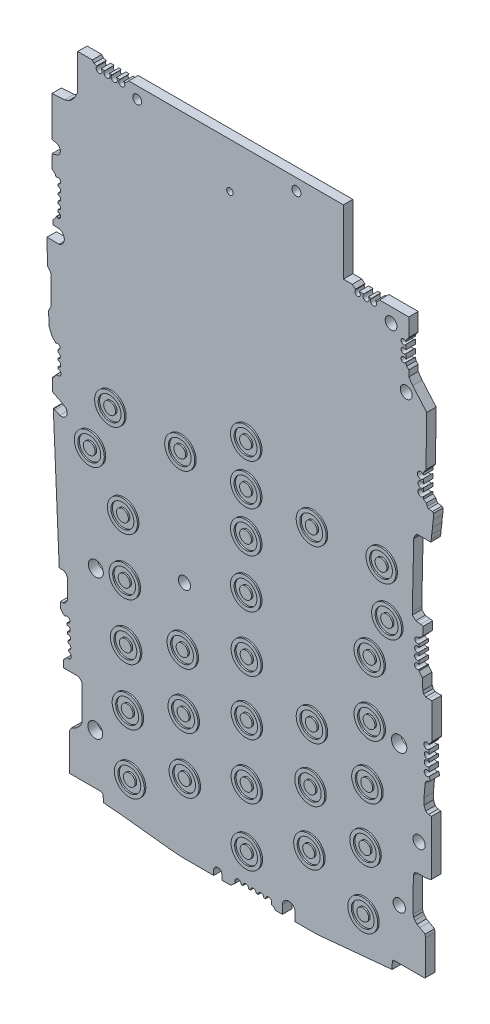
from build123d import *

# Parameters (mm, degrees)
PCBMAIN_R          = 0.760209253
PCBMAIN_R_2        = 0.759129565
PCBMAIN_R_3        = 0.996602967
PCBMAIN_R_4        = 1.012822949
PCBMAIN_R_5        = 0.551193265
PCBMAIN_R_6        = 1.025383556
PCBMAIN_R_7        = 1.032267377
PCBMAIN_R_8        = 1.041760337
PCBMAIN_R_9        = 1.256983707
PCBMAIN_R_10       = 1.269539046
PCBMAIN_R_11       = 1.299761266
BOSS_EXTRU_1_DEPTH = 1.6
BUTTONS_R          = 2.542017241
BUTTONS_R_2        = 1.938980707
BUTTONS_R_3        = 1.002648756
BOSS_EXTRU_2_DEPTH = 0.25


with BuildPart() as part:
    # pcbmain → Boss.-Extru.1 (new body)
    with BuildSketch(Plane.XY):
        with BuildLine():
            Line((-26.347160338, 56.329284646), (-23.927618791, 56.329284646))
            Line((-23.927618791, 56.329284646), (-23.664647578, 55.952821554))
            Line((-23.664647578, 55.952821554), (-23.201317346, 55.80255229))
            Line((-23.201317346, 55.80255229), (-23.128187119, 55.80255229))
            ThreePointArc((-23.128187119, 55.80255229), (-22.781212925, 54.930096236), (-22.434238731, 55.80255229))
            Line((-22.434238731, 55.80255229), (-21.828313295, 55.80255229))
            ThreePointArc((-21.828313295, 55.80255229), (-21.432210012, 54.909796767), (-21.036106729, 55.80255229))
            Line((-21.036106729, 55.80255229), (-20.591897878, 55.80255229))
            ThreePointArc((-20.591897878, 55.80255229), (-20.224453231, 54.890639566), (-19.857008583, 55.80255229))
            Line((-19.857008583, 55.80255229), (-19.266480451, 55.80255229))
            ThreePointArc((-19.266480451, 55.80255229), (-18.948553836, 54.880571738), (-18.630627221, 55.80255229))
            Line((-18.630627221, 55.80255229), (-18.279998937, 55.80255229))
            Line((-18.279998937, 55.80255229), (-17.77284017, 56.329284646))
            Line((-17.77284017, 56.329284646), (18.595018705, 56.329284646))
            Line((18.595018705, 56.329284646), (18.595018705, 45.429755694))
            Line((18.595018705, 45.429755694), (20.11132037, 45.429755694))
            Line((20.11132037, 45.429755694), (20.630107953, 44.97217823))
            Line((20.630107953, 44.97217823), (20.721658703, 44.97217823))
            ThreePointArc((20.721658703, 44.97217823), (20.992920184, 44.111471008), (21.264181665, 44.97217823))
            Line((21.264181665, 44.97217823), (22.033886118, 44.97217823))
            ThreePointArc((22.033886118, 44.97217823), (22.435692187, 44.083717269), (22.837498256, 44.97217823))
            Line((22.837498256, 44.97217823), (23.325768922, 44.97217823))
            ThreePointArc((23.325768922, 44.97217823), (23.685190384, 44.056278982), (24.044611847, 44.97217823))
            Line((24.044611847, 44.97217823), (24.431159458, 45.050165905))
            Line((24.431159458, 45.050165905), (24.705811707, 45.429755694))
            Line((24.705811707, 45.429755694), (29.675798929, 45.429755694))
            Line((29.675798929, 45.429755694), (29.675798929, 42.4053954))
            Line((29.675798929, 42.4053954), (29.182053315, 41.772560318))
            Line((29.182053315, 41.772560318), (29.182053315, 41.532362636))
            ThreePointArc((29.182053315, 41.532362636), (28.363974279, 41.344689092), (29.182053315, 41.157015548))
            Line((29.182053315, 41.157015548), (29.182053315, 40.343285981))
            ThreePointArc((29.182053315, 40.343285981), (28.359033494, 40.062491976), (29.182053315, 39.781697971))
            Line((29.182053315, 39.781697971), (29.182053315, 38.96510316))
            ThreePointArc((29.182053315, 38.96510316), (28.370622263, 38.728720451), (29.182053315, 38.492337743))
            Line((29.182053315, 38.492337743), (29.182053315, 38.433809714))
            Line((29.182053315, 38.433809714), (29.298436778, 37.997371726))
            Line((29.298436778, 37.997371726), (29.675798929, 37.655495303))
            Line((29.675798929, 37.655495303), (29.675798929, 36.627711227))
            Line((29.675798929, 36.627711227), (30.33297601, 35.686418365))
            Line((30.33297601, 35.686418365), (32.119853137, 33.617402745))
            Line((32.119853137, 33.617402745), (32.7131208, 32.930461239))
            Line((32.7131208, 32.930461239), (32.584297057, 24.478056045))
            Line((32.584297057, 24.478056045), (32.165274176, 23.839010992))
            Line((32.165274176, 23.839010992), (32.165274176, 23.430489137))
            ThreePointArc((32.165274176, 23.430489137), (31.135756508, 23.192400566), (32.165274176, 22.954311994))
            Line((32.165274176, 22.954311994), (32.165274176, 22.156317438))
            ThreePointArc((32.165274176, 22.156317438), (31.220854764, 21.883359432), (32.165274176, 21.610401425))
            Line((32.165274176, 21.610401425), (32.148127992, 20.964451154))
            ThreePointArc((32.148127992, 20.964451154), (31.212303724, 20.625077263), (32.148127992, 20.285703371))
            Line((32.148127992, 20.285703371), (32.165274176, 20.285703371))
            Line((32.165274176, 20.285703371), (32.165274176, 19.908565197))
            Line((32.165274176, 19.908565197), (32.630485989, 19.603525054))
            Line((32.630485989, 19.603525054), (32.804035512, 19.187083471))
            ThreePointArc((32.804035512, 19.187083471), (32.892709628, 19.053604885), (33.024845703, 18.962942383))
            Line((33.024845703, 18.962942383), (33.68655575, 18.892171255))
            Line((33.68655575, 18.892171255), (33.875985234, 18.716994969))
            Line((33.875985234, 18.716994969), (33.875985234, 17.80583444))
            Line((33.875985234, 17.80583444), (33.781270492, 17.80583444))
            Line((33.781270492, 17.80583444), (33.708220342, 16.575711613))
            Line((33.708220342, 16.575711613), (33.553914832, 15.418963886))
            Line((33.553914832, 15.418963886), (33.497779339, 14.741595603))
            Line((33.497779339, 14.741595603), (33.400128649, 14.251477155))
            Line((33.400128649, 14.251477155), (31.002556808, 14.251477155))
            Line((31.002556808, 14.251477155), (30.697220834, 13.785814174))
            Line((30.697220834, 13.785814174), (30.520636829, 13.392132333))
            Line((30.520636829, 13.392132333), (30.506039307, 13.215988906))
            Line((30.506039307, 13.215988906), (30.273104425, 2.473562529))
            Line((30.273104425, 2.473562529), (30.273104425, 1.988804395))
            Line((30.273104425, 1.988804395), (30.52208686, 1.758556085))
            Line((30.52208686, 1.758556085), (30.849888821, 1.455418848))
            Line((30.849888821, 1.455418848), (31.099307686, 1.405724892))
            Line((31.099307686, 1.405724892), (31.692843962, 1.356536803))
            Line((31.692843962, 1.356536803), (32.119853137, 1.271459939))
            Line((32.119853137, 1.271459939), (32.119853137, -0.124452781))
            Line((32.119853137, -0.124452781), (31.85383624, -0.354194647))
            Line((31.85383624, -0.354194647), (31.725758852, -0.549523411))
            Line((31.725758852, -0.549523411), (31.396075824, -0.686916827))
            Line((31.396075824, -0.686916827), (31.396075824, -0.913696889))
            ThreePointArc((31.396075824, -0.913696889), (30.681699235, -1.299026746), (31.396075824, -1.684356603))
            Line((31.396075824, -1.684356603), (31.396075824, -2.219700374))
            ThreePointArc((31.396075824, -2.219700374), (30.651157623, -2.575615737), (31.396075824, -2.931531101))
            Line((31.396075824, -2.931531101), (31.396075824, -3.425694582))
            ThreePointArc((31.396075824, -3.425694582), (30.640193016, -3.761019801), (31.396075824, -4.09634502))
            Line((31.396075824, -4.09634502), (31.396075824, -4.710368663))
            ThreePointArc((31.396075824, -4.710368663), (30.645561021, -5.077760093), (31.396075824, -5.445151523))
            Line((31.396075824, -5.445151523), (31.396075824, -5.653977426))
            Line((31.396075824, -5.653977426), (31.986844688, -6.338025585))
            Line((31.986844688, -6.338025585), (32.049056444, -8.19424299))
            Line((32.049056444, -8.19424299), (32.201342728, -8.651620718))
            Line((32.201342728, -8.651620718), (32.552324294, -8.881759902))
            Line((32.552324294, -8.881759902), (32.97533873, -8.916816346))
            Line((32.97533873, -8.916816346), (33.631067587, -8.916816346))
            Line((33.631067587, -8.916816346), (33.631067587, -14.886392836))
            Line((33.631067587, -14.886392836), (33.133289274, -15.509264135))
            Line((33.133289274, -15.509264135), (33.133289274, -15.613477346))
            ThreePointArc((33.133289274, -15.613477346), (32.240921556, -15.947205939), (33.133289274, -16.280934532))
            Line((33.133289274, -16.280934532), (33.133289274, -17.001434673))
            ThreePointArc((33.133289274, -17.001434673), (32.306209244, -17.319692403), (33.133289274, -17.637950134))
            Line((33.133289274, -17.637950134), (33.133289274, -18.186060671))
            ThreePointArc((33.133289274, -18.186060671), (32.299780119, -18.515369018), (33.133289274, -18.844677364))
            Line((33.133289274, -18.844677364), (33.133289274, -19.622640706))
            ThreePointArc((33.133289274, -19.622640706), (32.28219796, -19.941620213), (33.133289274, -20.26059972))
            Line((33.133289274, -20.26059972), (33.318842066, -20.817890321))
            Line((33.318842066, -20.817890321), (33.133289274, -20.97814046))
            Line((33.133289274, -20.97814046), (32.763831512, -21.101153335))
            Line((32.763831512, -21.101153335), (32.478949459, -21.45762699))
            Line((32.478949459, -21.45762699), (32.429964541, -21.703487125))
            Line((32.429964541, -21.703487125), (32.254768798, -23.817515757))
            Line((32.254768798, -23.817515757), (32.254768798, -24.910601341))
            Line((32.254768798, -24.910601341), (32.552324294, -25.624602049))
            Line((32.552324294, -25.624602049), (33.024845703, -25.895512052))
            Line((33.024845703, -25.895512052), (33.497779339, -25.934705447))
            Line((33.497779339, -25.934705447), (33.497779339, -35.190955042))
            Line((33.497779339, -35.190955042), (33.182319476, -35.32242104))
            Line((33.182319476, -35.32242104), (32.552324294, -35.41982665))
            Line((32.552324294, -35.41982665), (31.099307686, -35.41982665))
            Line((31.099307686, -35.41982665), (30.685987841, -35.592075206))
            Line((30.685987841, -35.592075206), (30.49409695, -35.926771429))
            Line((30.49409695, -35.926771429), (30.439368275, -36.201460044))
            Line((30.439368275, -36.201460044), (30.397595643, -41.788285256))
            Line((30.397595643, -41.788285256), (30.49409695, -42.243872097))
            Line((30.49409695, -42.243872097), (30.730517934, -42.582504394))
            Line((30.730517934, -42.582504394), (31.071644863, -42.97749347))
            Line((31.071644863, -42.97749347), (31.534036135, -43.242595576))
            Line((31.534036135, -43.242595576), (32.42996454, -43.734673871))
            Line((32.42996454, -43.734673871), (32.525500542, -44.185703465))
            Line((32.525500542, -44.185703465), (32.481143689, -50.118151883))
            Line((32.481143689, -50.118151883), (32.342366669, -50.215041045))
            Line((32.342366669, -50.215041045), (27.120149976, -50.215041045))
            Line((27.120149976, -50.215041045), (26.924465275, -50.384041469))
            Line((26.924465275, -50.384041469), (26.877788359, -50.618317516))
            Line((26.877788359, -50.618317516), (26.853968453, -51.716837329))
            Line((26.853968453, -51.716837329), (14.071547847, -52.924255816))
            Line((14.071547847, -52.924255816), (12.489702367, -52.924255816))
            Line((12.489702367, -52.924255816), (10.424778327, -52.924255816))
            Line((10.424778327, -52.924255816), (10.424778327, -51.512908651))
            ThreePointArc((10.424778327, -51.512908651), (9.344955664, -50.45112345), (8.265133001, -51.512908651))
            Line((8.265133001, -51.512908651), (8.265133001, -52.924255816))
            Line((8.265133001, -52.924255816), (7.07633639, -52.924255816))
            Line((7.07633639, -52.924255816), (6.749271755, -52.545549397))
            Line((6.749271755, -52.545549397), (6.459079051, -52.415384922))
            Line((6.459079051, -52.415384922), (6.459079051, -52.056713226))
            ThreePointArc((6.459079051, -52.056713226), (5.944041711, -51.530700307), (5.429004372, -52.056713226))
            Line((5.429004372, -52.056713226), (5.090721584, -52.056713226))
            ThreePointArc((5.090721584, -52.056713226), (4.629426873, -51.548790173), (4.168132162, -52.056713226))
            Line((4.168132162, -52.056713226), (3.77346891, -52.056713226))
            ThreePointArc((3.77346891, -52.056713226), (3.330113438, -51.546778738), (2.886757966, -52.056713226))
            Line((2.886757966, -52.056713226), (2.538224185, -52.056713226))
            ThreePointArc((2.538224185, -52.056713226), (2.056427487, -51.513404245), (1.574630789, -52.056713226))
            Line((1.574630789, -52.056713226), (1.297853962, -52.056713226))
            ThreePointArc((1.297853962, -52.056713226), (0.758160136, -51.495972188), (0.218466311, -52.056713226))
            Line((0.218466311, -52.056713226), (0.218466311, -52.415384922))
            Line((0.218466311, -52.415384922), (-0.495590455, -53.03207031))
            Line((-0.495590455, -53.03207031), (-1.985948048, -53.03207031))
            Line((-1.985948048, -53.03207031), (-1.985948048, -52.236049074))
            ThreePointArc((-1.985948048, -52.236049074), (-2.674664487, -51.508996718), (-3.363380926, -52.236049074))
            Line((-3.363380926, -52.236049074), (-3.363380926, -53.03207031))
            Line((-3.363380926, -53.03207031), (-8.756146039, -53.03207031))
            Line((-8.756146039, -53.03207031), (-11.011402522, -52.845170602))
            Line((-11.011402522, -52.845170602), (-17.162089801, -52.157450729))
            Line((-17.162089801, -52.157450729), (-19.133309089, -51.937045006))
            Line((-19.133309089, -51.937045006), (-21.33126485, -51.754893976))
            Line((-21.33126485, -51.754893976), (-22.056026337, -51.673857036))
            Line((-22.056026337, -51.673857036), (-22.09015522, -50.65555068))
            Line((-22.09015522, -50.65555068), (-22.176654824, -50.447990142))
            Line((-22.176654824, -50.447990142), (-22.328424078, -50.326701132))
            Line((-22.328424078, -50.326701132), (-22.648894059, -50.262851026))
            Line((-22.648894059, -50.262851026), (-27.79602202, -50.262851026))
            Line((-27.79602202, -50.262851026), (-27.79602202, -43.939529598))
            Line((-27.79602202, -43.939529598), (-27.481398322, -43.459702058))
            Line((-27.481398322, -43.459702058), (-27.052819823, -43.242595576))
            Line((-27.052819823, -43.242595576), (-26.734756314, -43.110044523))
            Line((-26.734756314, -43.110044523), (-26.280142309, -42.687259143))
            Line((-26.280142309, -42.687259143), (-25.90436736, -42.280909312))
            Line((-25.90436736, -42.280909312), (-25.748420404, -41.933236345))
            Line((-25.748420404, -41.933236345), (-25.696524508, -41.817538031))
            Line((-25.696524508, -41.817538031), (-25.652999175, -35.996300256))
            Line((-25.652999175, -35.996300256), (-25.732639991, -35.805197757))
            Line((-25.732639991, -35.805197757), (-25.90436736, -35.606355541))
            Line((-25.90436736, -35.606355541), (-26.056208264, -35.465939564))
            Line((-26.056208264, -35.465939564), (-26.174851421, -35.371123845))
            Line((-26.174851421, -35.371123845), (-26.347160338, -35.293835549))
            Line((-26.347160338, -35.293835549), (-28.835927315, -35.293835549))
            Line((-28.835927315, -35.293835549), (-28.835927315, -34.104342387))
            Line((-28.835927315, -34.104342387), (-28.497476373, -33.812043846))
            Line((-28.497476373, -33.812043846), (-28.280055962, -33.53998512))
            Line((-28.280055962, -33.53998512), (-28.10377817, -33.523334044))
            Line((-28.10377817, -33.523334044), (-27.855783776, -33.523334044))
            ThreePointArc((-27.855783776, -33.523334044), (-27.504215708, -32.952050234), (-27.931681942, -32.435099641))
            Line((-27.931681942, -32.435099641), (-27.950543168, -32.164665767))
            ThreePointArc((-27.950543168, -32.164665767), (-27.567889953, -31.677831784), (-28.014417616, -31.248828455))
            Line((-28.014417616, -31.248828455), (-28.040161873, -30.879705101))
            ThreePointArc((-28.040161873, -30.879705101), (-27.610999445, -30.418524093), (-28.100025068, -30.021381485))
            Line((-28.100025068, -30.021381485), (-28.126566018, -29.640835061))
            ThreePointArc((-28.126566018, -29.640835061), (-27.672421083, -29.156222915), (-28.189439903, -28.739343924))
            Line((-28.189439903, -28.739343924), (-28.214137423, -28.385228763))
            ThreePointArc((-28.214137423, -28.385228763), (-27.724239829, -27.876189637), (-28.280055962, -27.440083102))
            Line((-28.280055962, -27.440083102), (-28.666701844, -27.601215445))
            Line((-28.666701844, -27.601215445), (-28.805861595, -27.440083102))
            Line((-28.805861595, -27.440083102), (-29.30108279, -26.866669087))
            Line((-29.30108279, -26.866669087), (-29.30108279, -25.786096584))
            Line((-29.30108279, -25.786096584), (-28.882217901, -25.786096584))
            Line((-28.882217901, -25.786096584), (-28.54573806, -25.645870636))
            Line((-28.54573806, -25.645870636), (-28.344803607, -25.428587176))
            Line((-28.344803607, -25.428587176), (-28.162083432, -25.095908012))
            Line((-28.162083432, -25.095908012), (-28.140218205, -24.986164282))
            Line((-28.140218205, -24.986164282), (-28.140218205, -21.730313966))
            Line((-28.140218205, -21.730313966), (-28.201813445, -21.545318377))
            Line((-28.201813445, -21.545318377), (-28.35684667, -21.302467205))
            Line((-28.35684667, -21.302467205), (-28.530544254, -21.141839107))
            Line((-28.530544254, -21.141839107), (-28.681736718, -21.058798398))
            Line((-28.681736718, -21.058798398), (-28.865425298, -21.001930607))
            Line((-28.865425298, -21.001930607), (-29.449710783, -21.001930607))
            Line((-29.449710783, -21.001930607), (-29.538350449, -20.899295203))
            Line((-29.538350449, -20.899295203), (-30.538996806, 1.908114889))
            Line((-30.538996806, 1.908114889), (-30.444316667, 1.908114889))
            Line((-30.444316667, 1.908114889), (-30.241598916, 1.796774514))
            Line((-30.241598916, 1.796774514), (-29.449710783, 1.430424187))
            ThreePointArc((-29.449710783, 1.430424187), (-28.273085384, 1.995674391), (-28.713977981, 3.224319514))
            Line((-28.713977981, 3.224319514), (-29.274235218, 3.558056458))
            Line((-29.274235218, 3.558056458), (-30.693938959, 4.268210497))
            Line((-30.693938959, 4.268210497), (-30.716029439, 5.259101128))
            Line((-30.716029439, 5.259101128), (-30.716029439, 6.362872354))
            Line((-30.716029439, 6.362872354), (-30.548034372, 6.418807181))
            Line((-30.548034372, 6.418807181), (-30.148130993, 6.85124865))
            Line((-30.148130993, 6.85124865), (-30.08027615, 7.07042649))
            Line((-30.08027615, 7.07042649), (-30.00574886, 7.118003803))
            Line((-30.00574886, 7.118003803), (-29.757917067, 7.118003803))
            ThreePointArc((-29.757917067, 7.118003803), (-29.236732018, 7.589808248), (-29.757917067, 8.061612693))
            Line((-29.757917067, 8.061612693), (-29.757917067, 8.375406884))
            ThreePointArc((-29.757917067, 8.375406884), (-29.284052104, 8.859357079), (-29.757917067, 9.343307274))
            Line((-29.757917067, 9.343307274), (-29.757917067, 9.630583645))
            ThreePointArc((-29.757917067, 9.630583645), (-29.345861266, 10.083596385), (-29.757917067, 10.536609124))
            Line((-29.757917067, 10.536609124), (-29.757917067, 10.925537135))
            ThreePointArc((-29.757917067, 10.925537135), (-29.381423081, 11.367684509), (-29.757917067, 11.809831884))
            Line((-29.757917067, 11.809831884), (-30.127275882, 11.686851953))
            Line((-30.127275882, 11.686851953), (-30.632031906, 12.271306297))
            Line((-30.632031906, 12.271306297), (-30.847437712, 12.520723546))
            Line((-30.847437712, 12.520723546), (-30.9767092, 12.90897847))
            Line((-30.9767092, 12.90897847), (-31.245719259, 13.554482838))
            Line((-31.245719259, 13.554482838), (-31.346726424, 15.856706607))
            Line((-31.346726424, 15.856706607), (-31.082678328, 16.384578093))
            Line((-31.082678328, 16.384578093), (-30.959348757, 16.563560389))
            Line((-30.959348757, 16.563560389), (-30.959348757, 21.487696484))
            Line((-30.959348757, 21.487696484), (-31.048055304, 21.700552702))
            Line((-31.048055304, 21.700552702), (-31.280361883, 22.035905067))
            Line((-31.280361883, 22.035905067), (-31.519894462, 22.287784686))
            Line((-31.519894462, 22.287784686), (-31.613302175, 26.477681308))
            Line((-31.613302175, 26.477681308), (-29.538350448, 26.477681308))
            ThreePointArc((-29.538350448, 26.477681308), (-28.675344429, 27.618591739), (-29.538350448, 28.759502171))
            Line((-29.538350448, 28.759502171), (-30.606186251, 28.787986781))
            Line((-30.606186251, 28.787986781), (-30.606186251, 29.538528583))
            Line((-30.606186251, 29.538528583), (-30.137786662, 30.045039445))
            Line((-30.137786662, 30.045039445), (-30.059668538, 30.2973687))
            Line((-30.059668538, 30.2973687), (-29.942596474, 30.2973687))
            Line((-29.942596474, 30.2973687), (-29.752463198, 30.202261594))
            Line((-29.752463198, 30.202261594), (-29.708193938, 30.202261594))
            ThreePointArc((-29.708193938, 30.202261594), (-29.294249947, 30.643075824), (-29.708193939, 31.083890053))
            Line((-29.708193939, 31.083890053), (-29.708193939, 31.51248286))
            ThreePointArc((-29.708193939, 31.51248286), (-29.295642871, 31.925033928), (-29.708193939, 32.337584996))
            Line((-29.708193939, 32.337584996), (-29.708193939, 32.75754716))
            ThreePointArc((-29.708193939, 32.75754716), (-29.29070214, 33.17503896), (-29.708193939, 33.592530759))
            Line((-29.708193939, 33.592530759), (-29.708193939, 33.934964901))
            ThreePointArc((-29.708193939, 33.934964901), (-29.286784303, 34.394390042), (-29.708193939, 34.853815182))
            Line((-29.708193939, 34.853815182), (-29.708193939, 35.253187041))
            ThreePointArc((-29.708193939, 35.253187041), (-29.286260571, 35.728394619), (-29.708193939, 36.203602198))
            Line((-29.708193939, 36.203602198), (-30.059668538, 36.057127275))
            Line((-30.059668538, 36.057127275), (-30.241598916, 36.493679179))
            Line((-30.241598916, 36.493679179), (-30.491656736, 36.724921959))
            Line((-30.491656736, 36.724921959), (-30.739734809, 36.849013796))
            Line((-30.739734809, 36.849013796), (-30.716029439, 39.200054148))
            Line((-30.716029439, 39.200054148), (-30.444316666, 39.21900457))
            Line((-30.444316666, 39.21900457), (-30.150633727, 39.316787826))
            ThreePointArc((-30.150633727, 39.316787826), (-29.352231161, 40.219559463), (-30.150633727, 41.1223311))
            Line((-30.150633727, 41.1223311), (-30.470833326, 41.186127335))
            Line((-30.470833326, 41.186127335), (-30.763263321, 41.244390784))
            Line((-30.763263321, 41.244390784), (-30.781709042, 41.261448597))
            Line((-30.781709042, 41.261448597), (-30.781709042, 47.983356406))
            Line((-30.781709042, 47.983356406), (-28.606140486, 48.135089951))
            Line((-28.606140486, 48.135089951), (-27.932867448, 48.359259696))
            Line((-27.932867448, 48.359259696), (-27.374131041, 48.746309728))
            Line((-27.374131041, 48.746309728), (-26.910650535, 49.32626409))
            Line((-26.910650535, 49.32626409), (-26.60739875, 49.932509594))
            Line((-26.60739875, 49.932509594), (-26.402277568, 50.342577401))
            Line((-26.402277568, 50.342577401), (-26.402277568, 56.329284646))
            Line((-26.402277568, 56.329284646), (-26.347160338, 56.329284646))
        make_face()
        with Locations((-16.322275109, 54.329974326)):
            Circle(PCBMAIN_R, mode=Mode.SUBTRACT)
        with Locations((10.647879553, 54.382207034)):
            Circle(PCBMAIN_R_2, mode=Mode.SUBTRACT)
        with Locations((26.673871891, 43.003417738)):
            Circle(PCBMAIN_R_3, mode=Mode.SUBTRACT)
        with Locations((29.239982162, 34.176185645)):
            Circle(PCBMAIN_R_4, mode=Mode.SUBTRACT)
        with Locations((-0.618009829, 48.676607835)):
            Circle(PCBMAIN_R_5, mode=Mode.SUBTRACT)
        with Locations((-8.326120201, -12.582181563)):
            Circle(PCBMAIN_R_6, mode=Mode.SUBTRACT)
        with Locations((31.417024073, -30.721878393)):
            Circle(PCBMAIN_R_7, mode=Mode.SUBTRACT)
        with Locations((28.062026174, -41.694439649)):
            Circle(PCBMAIN_R_8, mode=Mode.SUBTRACT)
        with Locations((-23.426533368, -41.711658863)):
            Circle(PCBMAIN_R_9, mode=Mode.SUBTRACT)
        with Locations((-23.339901388, -17.987525001)):
            Circle(PCBMAIN_R_10, mode=Mode.SUBTRACT)
        with Locations((28.037388114, -17.977376606)):
            Circle(PCBMAIN_R_11, mode=Mode.SUBTRACT)
    extrude(amount=-BOSS_EXTRU_1_DEPTH)

    # buttons → Boss.-Extru.2 (add)
    with BuildSketch(Plane.XY):
        with Locations((2.26801536, 13.484442035)):
            Circle(BUTTONS_R)
        with Locations((2.26801536, 13.484442035)):
            Circle(BUTTONS_R_2, mode=Mode.SUBTRACT)
        with Locations((2.26801536, 13.484442035)):
            Circle(BUTTONS_R_3)
        with Locations((-20.751412242, 6.956708227)):
            Circle(BUTTONS_R)
        with Locations((-20.751412242, 6.956708227)):
            Circle(BUTTONS_R_2, mode=Mode.SUBTRACT)
        with Locations((-20.751412242, 6.956708227)):
            Circle(BUTTONS_R_3)
        with Locations((-24.19539584, -0.654148345)):
            Circle(BUTTONS_R)
        with Locations((-24.19539584, -0.654148345)):
            Circle(BUTTONS_R_2, mode=Mode.SUBTRACT)
        with Locations((-24.19539584, -0.654148345)):
            Circle(BUTTONS_R_3)
        with Locations((-8.883460378, 6.451898361)):
            Circle(BUTTONS_R)
        with Locations((-8.883460378, 6.451898361)):
            Circle(BUTTONS_R_2, mode=Mode.SUBTRACT)
        with Locations((-8.883460378, 6.515932643)):
            Circle(BUTTONS_R_3)
        with Locations((2.26801536, 6.515932643)):
            Circle(BUTTONS_R)
        with Locations((2.26801536, 6.515932643)):
            Circle(BUTTONS_R_2, mode=Mode.SUBTRACT)
        with Locations((2.26801536, 6.515932643)):
            Circle(BUTTONS_R_3)
        with Locations((2.26801536, -0.395198907)):
            Circle(BUTTONS_R)
        with Locations((2.26801536, -0.395198907)):
            Circle(BUTTONS_R_2, mode=Mode.SUBTRACT)
        with Locations((2.26801536, -0.395198907)):
            Circle(BUTTONS_R_3)
        with Locations((-18.582141448, -7.691228412)):
            Circle(BUTTONS_R)
        with Locations((-18.582141448, -7.691228412)):
            Circle(BUTTONS_R_2, mode=Mode.SUBTRACT)
        with Locations((-18.582141448, -7.691228412)):
            Circle(BUTTONS_R_3)
        with Locations((13.397486211, 6.515932643)):
            Circle(BUTTONS_R)
        with Locations((13.397486211, 6.515932643)):
            Circle(BUTTONS_R_2, mode=Mode.SUBTRACT)
        with Locations((13.397486211, 6.515932643)):
            Circle(BUTTONS_R_3)
        with Locations((25.213123744, 6.956708227)):
            Circle(BUTTONS_R)
        with Locations((25.213123744, 6.956708227)):
            Circle(BUTTONS_R_2, mode=Mode.SUBTRACT)
        with Locations((25.213123744, 6.956708227)):
            Circle(BUTTONS_R_3)
        with Locations((26.165334099, -0.780416573)):
            Circle(BUTTONS_R)
        with Locations((26.165334099, -0.780416573)):
            Circle(BUTTONS_R_2, mode=Mode.SUBTRACT)
        with Locations((26.165334099, -0.780416573)):
            Circle(BUTTONS_R_3)
        with Locations((2.26801536, -8.624608424)):
            Circle(BUTTONS_R)
        with Locations((2.26801536, -8.624608424)):
            Circle(BUTTONS_R_2, mode=Mode.SUBTRACT)
        with Locations((2.26801536, -8.624608424)):
            Circle(BUTTONS_R_3)
        with Locations((23.189861833, -7.691228412)):
            Circle(BUTTONS_R)
        with Locations((23.189861833, -7.691228412)):
            Circle(BUTTONS_R_2, mode=Mode.SUBTRACT)
        with Locations((23.189861833, -7.691228412)):
            Circle(BUTTONS_R_3)
        with Locations((-18.297343936, -17.127558811)):
            Circle(BUTTONS_R)
        with Locations((-18.297343936, -17.127558811)):
            Circle(BUTTONS_R_2, mode=Mode.SUBTRACT)
        with Locations((-18.297343936, -17.127558811)):
            Circle(BUTTONS_R_3)
        with Locations((-8.481583469, -22.392577408)):
            Circle(BUTTONS_R)
        with Locations((-8.481583469, -22.392577408)):
            Circle(BUTTONS_R_2, mode=Mode.SUBTRACT)
        with Locations((-8.481583469, -22.392577408)):
            Circle(BUTTONS_R_3)
        with Locations((-18.086208531, -26.524269945)):
            Circle(BUTTONS_R)
        with Locations((-18.086208531, -26.524269945)):
            Circle(BUTTONS_R_2, mode=Mode.SUBTRACT)
        with Locations((-18.086208531, -26.524269945)):
            Circle(BUTTONS_R_3)
        with Locations((2.365002645, -18.027026928)):
            Circle(BUTTONS_R)
        with Locations((2.365002645, -18.027026928)):
            Circle(BUTTONS_R_2, mode=Mode.SUBTRACT)
        with Locations((2.365002645, -18.027026928)):
            Circle(BUTTONS_R_3)
        with Locations((23.189861833, -17.127558811)):
            Circle(BUTTONS_R)
        with Locations((23.189861833, -17.127558811)):
            Circle(BUTTONS_R_2, mode=Mode.SUBTRACT)
        with Locations((23.189861833, -17.127558811)):
            Circle(BUTTONS_R_3)
        with Locations((13.397486211, -22.392577408)):
            Circle(BUTTONS_R)
        with Locations((13.397486211, -22.392577408)):
            Circle(BUTTONS_R_2, mode=Mode.SUBTRACT)
        with Locations((13.397486211, -22.392577408)):
            Circle(BUTTONS_R_3)
        with Locations((22.790521393, -26.524269945)):
            Circle(BUTTONS_R)
        with Locations((22.790521393, -26.524269945)):
            Circle(BUTTONS_R_2, mode=Mode.SUBTRACT)
        with Locations((22.790521393, -26.524269945)):
            Circle(BUTTONS_R_3)
        with Locations((2.365002645, -27.311841842)):
            Circle(BUTTONS_R)
        with Locations((2.365002645, -27.311841842)):
            Circle(BUTTONS_R_2, mode=Mode.SUBTRACT)
        with Locations((2.365002645, -27.311841842)):
            Circle(BUTTONS_R_3)
        with Locations((13.151340273, -31.739260798)):
            Circle(BUTTONS_R)
        with Locations((13.151340273, -31.739260798)):
            Circle(BUTTONS_R_2, mode=Mode.SUBTRACT)
        with Locations((13.151340273, -31.739260798)):
            Circle(BUTTONS_R_3)
        with Locations((-8.316509061, -31.739260798)):
            Circle(BUTTONS_R)
        with Locations((-8.316509061, -31.739260798)):
            Circle(BUTTONS_R_2, mode=Mode.SUBTRACT)
        with Locations((-8.316509061, -31.739260798)):
            Circle(BUTTONS_R_3)
        with Locations((-17.7801679, -35.951265509)):
            Circle(BUTTONS_R)
        with Locations((-17.7801679, -35.951265509)):
            Circle(BUTTONS_R_2, mode=Mode.SUBTRACT)
        with Locations((-17.7801679, -35.951265509)):
            Circle(BUTTONS_R_3)
        with Locations((-8.140103678, -41.137198245)):
            Circle(BUTTONS_R)
        with Locations((-8.140103678, -41.137198245)):
            Circle(BUTTONS_R_2, mode=Mode.SUBTRACT)
        with Locations((-8.140103678, -41.137198245)):
            Circle(BUTTONS_R_3)
        with Locations((-17.411460334, -45.896228607)):
            Circle(BUTTONS_R)
        with Locations((-17.411460334, -45.896228607)):
            Circle(BUTTONS_R_2, mode=Mode.SUBTRACT)
        with Locations((-17.411460334, -45.896228607)):
            Circle(BUTTONS_R_3)
        with Locations((2.365002645, -36.727721144)):
            Circle(BUTTONS_R)
        with Locations((2.365002645, -36.727721144)):
            Circle(BUTTONS_R_2, mode=Mode.SUBTRACT)
        with Locations((2.365002645, -36.727721144)):
            Circle(BUTTONS_R_3)
        with Locations((22.476444593, -35.951265509)):
            Circle(BUTTONS_R)
        with Locations((22.476444593, -35.951265509)):
            Circle(BUTTONS_R_2, mode=Mode.SUBTRACT)
        with Locations((22.476444593, -35.951265509)):
            Circle(BUTTONS_R_3)
        with Locations((12.961877713, -41.137198245)):
            Circle(BUTTONS_R)
        with Locations((12.961877713, -41.137198245)):
            Circle(BUTTONS_R_2, mode=Mode.SUBTRACT)
        with Locations((12.961877713, -41.137198245)):
            Circle(BUTTONS_R_3)
        with Locations((2.365002645, -46.582278384)):
            Circle(BUTTONS_R)
        with Locations((2.365002645, -46.582278384)):
            Circle(BUTTONS_R_2, mode=Mode.SUBTRACT)
        with Locations((2.365002645, -46.582278384)):
            Circle(BUTTONS_R_3)
        with Locations((22.1278939, -45.896228607)):
            Circle(BUTTONS_R)
        with Locations((22.1278939, -45.896228607)):
            Circle(BUTTONS_R_2, mode=Mode.SUBTRACT)
        with Locations((22.1278939, -45.896228607)):
            Circle(BUTTONS_R_3)
    extrude(amount=BOSS_EXTRU_2_DEPTH)


solid = part.part
